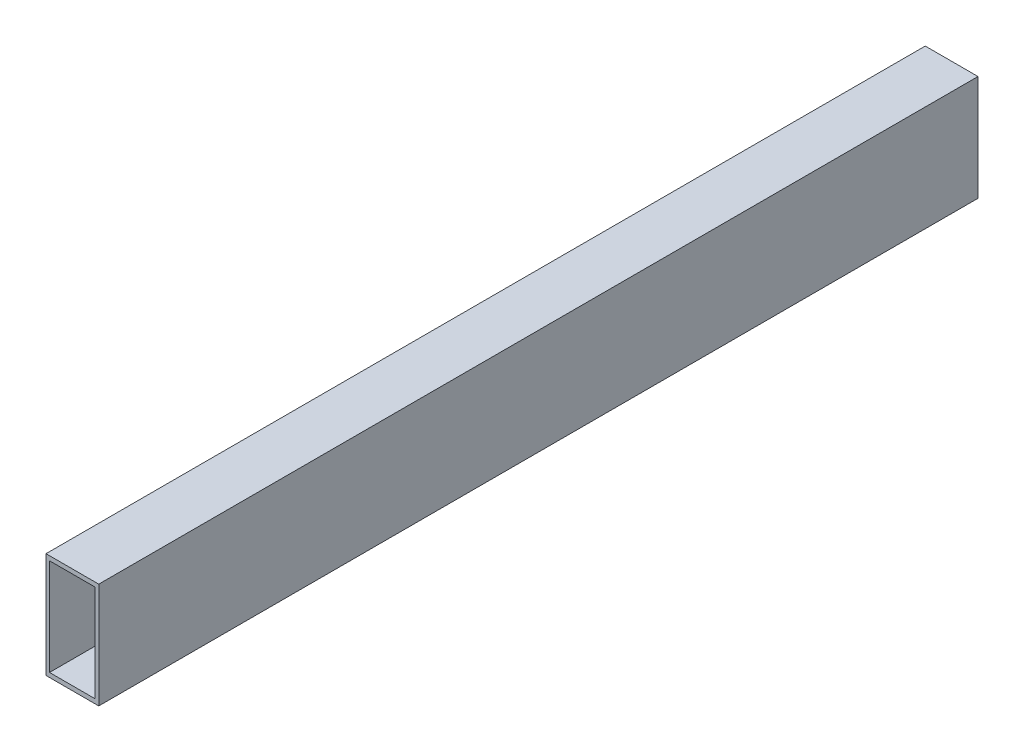
from build123d import *

# Parameters (mm, degrees)
SKETCH1_W   = 60
SKETCH1_H   = 120
SKETCH1_W_2 = 52
SKETCH1_H_2 = 110


with BuildPart() as part:
    # Sweep1: sweep along a curve in space
    with BuildLine() as sweep1_path:
        add(Edge.make_bspline(
            [(0, 0, -500), (0, 0, 500)],
            knots=[0, 0, 1, 1], degree=1))
    # Sketch1 → Sweep1 (sweep)
    with BuildSketch(Plane.XY):
        Rectangle(SKETCH1_W, SKETCH1_H)
        Rectangle(SKETCH1_W_2, SKETCH1_H_2, mode=Mode.SUBTRACT)
    sweep(path=sweep1_path.line)


solid = part.part
